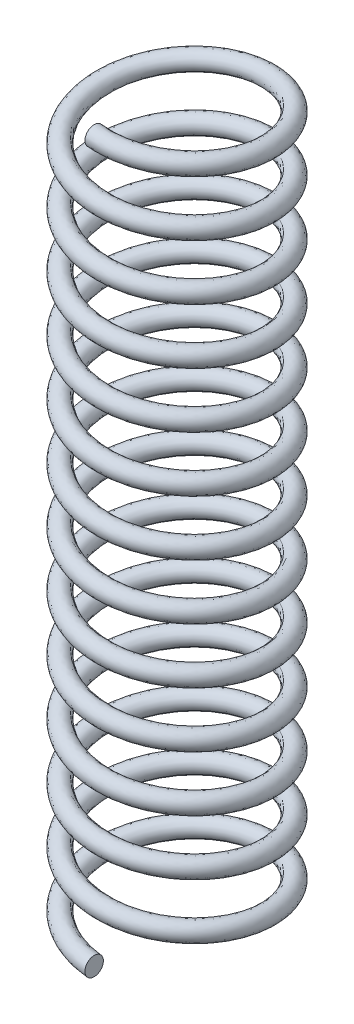
from build123d import *

# Parameters (mm, degrees)
SWEEP1_PITCH  = 19.05
SWEEP1_HEIGHT = 247.65
SWEEP1_RADIUS = 28.575
SKETCH2_R     = 3.175


with BuildPart() as part:
    # Sweep1: sweep along a helix
    with BuildLine() as sweep1_path:
        Helix(SWEEP1_PITCH, SWEEP1_HEIGHT, SWEEP1_RADIUS, center=(0, 0, 0), direction=(0, 1, 0), lefthand=True)
    # Sketch2 → Sweep1 (sweep)
    with BuildSketch(Plane(origin=(0, 0, 0), x_dir=(0, 0, -1), z_dir=(1, 0, 0))):
        with Locations((-28.511485458, 0)):
            Circle(SKETCH2_R)
    sweep(path=sweep1_path.line, is_frenet=True)


solid = part.part
